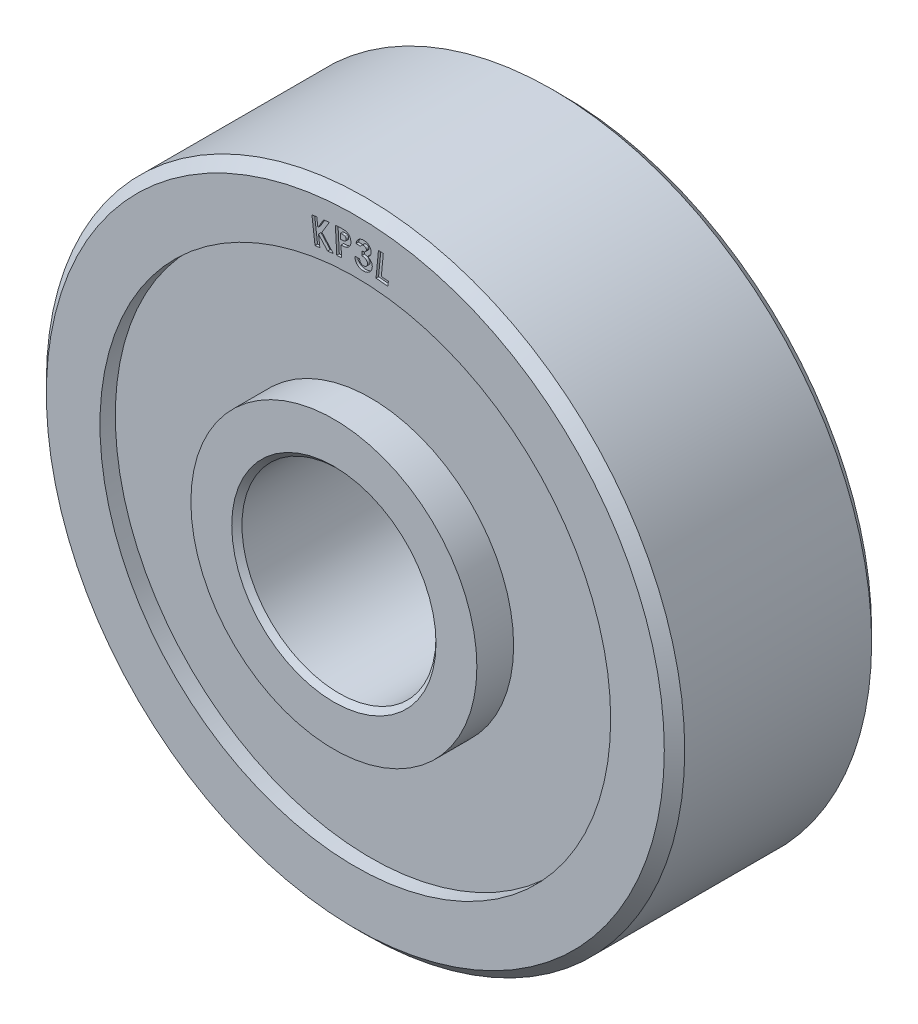
from build123d import *

# Parameters (mm, degrees)
CUT_EXTRUDE1_DEPTH = 0.0635


with BuildPart() as part:
    # Sketch1 → Revolve1 (revolve)
    with BuildSketch(Plane(origin=(0, 0, 0), x_dir=(0, 0, -1), z_dir=(1, 0, 0))):
        Polygon((-3.1115, 2.54), (-3.1115, 3.556), (-2.1971, 3.556), (-2.1971, 6.35), (-2.5781, 6.35), (-2.5781, 7.6835), (-2.3241, 7.9375), (2.3241, 7.9375), (2.5781, 7.6835), (2.5781, 6.35), (2.1971, 6.35), (2.1971, 3.556), (3.1115, 3.556), (3.1115, 2.54), (2.9845, 2.413), (-2.9845, 2.413), align=None)
    revolve(axis=Axis((0, 0, 0), (0, 0, -1)))

    # Sketch2 → Cut-Extrude1 (cut)
    with BuildSketch(Plane.XY.offset(2.5781)):
        Polygon((-1.079278431, 7.150586302), (-0.958816692, 7.165341911), (-0.932358358, 6.950113546), (-0.789127189, 7.186203289), (-0.645768815, 7.203757376), (-0.830213927, 6.897832896), (-0.547694897, 6.580714507), (-0.68889081, 6.563287624), (-0.916076307, 6.817313065), (-0.881985762, 6.539627768), (-1.002447501, 6.524872159), align=None)
        with BuildLine():
            Line((-0.495979722, 7.217923923), (-0.368521789, 7.224792914))
            add(Edge.make_bspline(
                [(-0.368521789, 7.224792914), (-0.360212666, 7.225170877), (-0.344150947, 7.225901489), (-0.320947535, 7.226328926), (-0.29948116, 7.22593657), (-0.27983437, 7.224960601), (-0.26191306, 7.223354515), (-0.245796038, 7.221018467), (-0.231439233, 7.217820211), (-0.218616257, 7.214006305), (-0.206993887, 7.20932123), (-0.196104896, 7.20396297), (-0.185829099, 7.197800596), (-0.175886108, 7.191127057), (-0.166827975, 7.183296649), (-0.15821902, 7.174861669), (-0.150205011, 7.165659009), (-0.142705457, 7.155796819), (-0.135950471, 7.145199124), (-0.129991296, 7.133997768), (-0.124746833, 7.122230733), (-0.120261866, 7.109877238), (-0.116755714, 7.096880858), (-0.113969598, 7.083372622), (-0.111855418, 7.069320908), (-0.111245338, 7.059732154), (-0.11093465, 7.054849003)],
                knots=[0, 0, 0, 0, 2.4953e-05, 4.8234e-05, 6.9608e-05, 8.935e-05, 0.000107236, 0.00012357, 0.000138168, 0.000151326, 0.000163656, 0.000175717, 0.000187693, 0.000199584, 0.000211588, 0.000223551, 0.000235721, 0.000248161, 0.000260688, 0.000273379, 0.000286191, 0.000299308, 0.000312763, 0.000326534, 0.000340673, 0.000355347, 0.000355347, 0.000355347, 0.000355347], degree=3))
            add(Edge.make_bspline(
                [(-0.11093465, 7.054849003), (-0.110712208, 7.049463954), (-0.110274042, 7.038856482), (-0.111260519, 7.023250479), (-0.113172236, 7.008253328), (-0.115979501, 6.993862027), (-0.120280665, 6.980201042), (-0.125502413, 6.967120052), (-0.131815769, 6.954637956), (-0.139429175, 6.94295352), (-0.147744879, 6.931849276), (-0.157121576, 6.921682198), (-0.16719465, 6.912185967), (-0.17816929, 6.903558165), (-0.189907814, 6.895658245), (-0.202410471, 6.888479224), (-0.215833366, 6.882227542), (-0.225221483, 6.878774839), (-0.22999715, 6.877018475)],
                knots=[0, 0, 0, 0, 1.6159e-05, 3.1831e-05, 4.6835e-05, 6.1504e-05, 7.5747e-05, 8.9731e-05, 0.000103726, 0.000117628, 0.000131519, 0.000145295, 0.000159065, 0.000173011, 0.000187123, 0.00020148, 0.00021622, 0.00023148, 0.00023148, 0.00023148, 0.00023148], degree=3))
            add(Edge.make_bspline(
                [(-0.22999715, 6.877018475), (-0.233124685, 6.876048914), (-0.239956759, 6.873930916), (-0.251226836, 6.871359321), (-0.26429545, 6.868935856), (-0.279152272, 6.866813438), (-0.295831543, 6.864965084), (-0.314313901, 6.863141326), (-0.334593332, 6.861681825), (-0.348719697, 6.860808402), (-0.356055844, 6.860354813)],
                knots=[0, 0, 0, 0, 9.82e-06, 2.1452e-05, 3.465e-05, 4.9689e-05, 6.6462e-05, 8.4992e-05, 0.000105402, 0.000127452, 0.000127452, 0.000127452, 0.000127452], degree=3))
            Line((-0.356055844, 6.860354813), (-0.341554642, 6.592845798))
            Line((-0.341554642, 6.592845798), (-0.461761973, 6.586358418))
            Line((-0.461761973, 6.586358418), (-0.495979722, 7.217923923))
        make_face()
        with BuildLine():
            Line((-0.36241602, 6.97750926), (-0.324254962, 6.979544516))
            add(Edge.make_bspline(
                [(-0.324254962, 6.979544516), (-0.317336689, 6.9799779), (-0.30457489, 6.980777342), (-0.287251836, 6.982919527), (-0.273270267, 6.985391536), (-0.262381832, 6.988846741), (-0.253744174, 6.993269306), (-0.246573864, 6.998590644), (-0.240166571, 7.004690808), (-0.235137389, 7.012026135), (-0.231168805, 7.020125976), (-0.22826413, 7.028965777), (-0.227100928, 7.038620455), (-0.227165491, 7.04522278), (-0.227198672, 7.048616031)],
                knots=[0, 0, 0, 0, 2.079e-05, 3.8351e-05, 5.2346e-05, 6.3328e-05, 7.2487e-05, 8.1316e-05, 9.0041e-05, 9.8899e-05, 0.00010783, 0.000117043, 0.000126667, 0.000136844, 0.000136844, 0.000136844, 0.000136844], degree=3))
            add(Edge.make_bspline(
                [(-0.227198672, 7.048616031), (-0.227427705, 7.051549895), (-0.227873088, 7.057255149), (-0.229642727, 7.065434523), (-0.232402977, 7.072908038), (-0.235754963, 7.079834319), (-0.240186228, 7.08601448), (-0.245412186, 7.091546709), (-0.251632427, 7.096260741), (-0.256171905, 7.098908266), (-0.258490739, 7.100260662)],
                knots=[0, 0, 0, 0, 8.822e-06, 1.7156e-05, 2.5002e-05, 3.2682e-05, 4.0164e-05, 4.7722e-05, 5.5431e-05, 6.3481e-05, 6.3481e-05, 6.3481e-05, 6.3481e-05], degree=3))
            add(Edge.make_bspline(
                [(-0.258490739, 7.100260662), (-0.260424076, 7.1011524), (-0.264539471, 7.103050595), (-0.271515666, 7.105142732), (-0.279542151, 7.106932906), (-0.288692612, 7.108156212), (-0.29888814, 7.108858012), (-0.310132208, 7.109270509), (-0.322479434, 7.109086136), (-0.331082448, 7.108720089), (-0.335576076, 7.108528891)],
                knots=[0, 0, 0, 0, 6.38e-06, 1.3582e-05, 2.1791e-05, 3.1038e-05, 4.1243e-05, 5.2443e-05, 6.4782e-05, 7.8276e-05, 7.8276e-05, 7.8276e-05, 7.8276e-05], degree=3))
            Line((-0.335576076, 7.108528891), (-0.369412214, 7.106748042))
            Line((-0.369412214, 7.106748042), (-0.36241602, 6.97750926))
        make_face(mode=Mode.SUBTRACT)
        with BuildLine():
            Line((0.132952806, 7.075773457), (0.017452005, 7.078444732))
            add(Edge.make_bspline(
                [(0.017452005, 7.078444732), (0.018439502, 7.084140821), (0.02036877, 7.095269235), (0.024442732, 7.111454443), (0.02968473, 7.126689428), (0.035796855, 7.141101973), (0.042752408, 7.154721258), (0.050980538, 7.167270992), (0.059964236, 7.179124945), (0.066817376, 7.186208566), (0.070241468, 7.189747816)],
                knots=[0, 0, 0, 0, 1.7339e-05, 3.3876e-05, 5.0007e-05, 6.5624e-05, 8.0814e-05, 9.581e-05, 0.000110592, 0.000125353, 0.000125353, 0.000125353, 0.000125353], degree=3))
            add(Edge.make_bspline(
                [(0.070241468, 7.189747816), (0.075192439, 7.194396641), (0.084970062, 7.203577557), (0.101150249, 7.215276904), (0.118160824, 7.225212143), (0.136146121, 7.233001378), (0.154887577, 7.239258861), (0.174558992, 7.243383937), (0.195137536, 7.24575924), (0.20914139, 7.245731494), (0.216271115, 7.245717368)],
                knots=[0, 0, 0, 0, 2.0357e-05, 4.0202e-05, 5.9751e-05, 7.9344e-05, 9.8893e-05, 0.000118928, 0.000139535, 0.000160908, 0.000160908, 0.000160908, 0.000160908], degree=3))
            add(Edge.make_bspline(
                [(0.216271115, 7.245717368), (0.222643467, 7.245466741), (0.235151233, 7.244974808), (0.253386088, 7.242017246), (0.270855675, 7.237931701), (0.287404435, 7.2319532), (0.30331457, 7.224796151), (0.318192998, 7.215727901), (0.332473067, 7.205471618), (0.345463167, 7.193482998), (0.357578641, 7.18085237), (0.367877659, 7.167233243), (0.376733752, 7.153233008), (0.383946054, 7.138680055), (0.389270466, 7.123490973), (0.393157806, 7.107832343), (0.395181679, 7.091559114), (0.395309178, 7.080569756), (0.39537368, 7.075010236)],
                knots=[0, 0, 0, 0, 1.9115e-05, 3.7519e-05, 5.5321e-05, 7.2862e-05, 9.0222e-05, 0.000107565, 0.000125044, 0.000142876, 0.000160514, 0.000177484, 0.000194001, 0.000210157, 0.00022609, 0.000242194, 0.000258477, 0.000275148, 0.000275148, 0.000275148, 0.000275148], degree=3))
            add(Edge.make_bspline(
                [(0.39537368, 7.075010236), (0.394948635, 7.068113053), (0.394112348, 7.054542638), (0.389195825, 7.034731031), (0.381559766, 7.015944127), (0.370990163, 6.998289072), (0.357888482, 6.981930636), (0.341973374, 6.967324387), (0.323568287, 6.954335464), (0.309826078, 6.947500387), (0.302769513, 6.943990605)],
                knots=[0, 0, 0, 0, 2.0695e-05, 4.0718e-05, 6.0915e-05, 8.1334e-05, 0.000102233, 0.000123566, 0.000145939, 0.000169554, 0.000169554, 0.000169554, 0.000169554], degree=3))
            add(Edge.make_bspline(
                [(0.302769513, 6.943990605), (0.307410197, 6.942346114), (0.316543415, 6.939109632), (0.329714867, 6.933441478), (0.341966279, 6.926702638), (0.353553282, 6.919456552), (0.364163573, 6.911144273), (0.374175204, 6.902319711), (0.3831394, 6.892437959), (0.391453576, 6.882031606), (0.398832047, 6.87097474), (0.405172288, 6.859381433), (0.410586141, 6.847416845), (0.414753855, 6.834905001), (0.418129223, 6.822003125), (0.420171265, 6.808572723), (0.421593917, 6.794769054), (0.42149875, 6.785413976), (0.421450402, 6.780661278)],
                knots=[0, 0, 0, 0, 1.4769e-05, 2.9067e-05, 4.2955e-05, 5.6682e-05, 7.0014e-05, 8.3345e-05, 9.6668e-05, 0.000109979, 0.000123279, 0.000136487, 0.000149583, 0.000162617, 0.000176006, 0.000189537, 0.000203333, 0.000217581, 0.000217581, 0.000217581, 0.000217581], degree=3))
            add(Edge.make_bspline(
                [(0.421450402, 6.780661278), (0.421137547, 6.773692656), (0.420521475, 6.759970097), (0.416962861, 6.73989903), (0.411608007, 6.720680255), (0.404369139, 6.702253524), (0.394989968, 6.684764153), (0.383739054, 6.66813578), (0.370500347, 6.652435227), (0.355614031, 6.637640856), (0.339196026, 6.624217045), (0.321513765, 6.6126142), (0.30292282, 6.60268693), (0.283132961, 6.595031176), (0.262467464, 6.588750355), (0.240650353, 6.584861887), (0.217854829, 6.582417398), (0.202327811, 6.582457625), (0.194392109, 6.582478185)],
                knots=[0, 0, 0, 0, 2.0908e-05, 4.1172e-05, 6.0987e-05, 8.0687e-05, 0.000100433, 0.000120402, 0.00014081, 0.000161947, 0.000183284, 0.000204311, 0.000225307, 0.000246378, 0.00026787, 0.00029, 0.000312757, 0.000336547, 0.000336547, 0.000336547, 0.000336547], degree=3))
            add(Edge.make_bspline(
                [(0.194392109, 6.582478185), (0.186919369, 6.58282211), (0.172255171, 6.583497015), (0.150835798, 6.586574284), (0.130497736, 6.591357491), (0.111348115, 6.598083664), (0.093157646, 6.606157207), (0.076136666, 6.61614531), (0.060312838, 6.627964977), (0.045551967, 6.641275516), (0.032219364, 6.656095091), (0.020628377, 6.672290052), (0.010395444, 6.689520266), (0.002265312, 6.70822003), (-0.004597546, 6.727960124), (-0.009429015, 6.748999425), (-0.013018339, 6.771178485), (-0.013814397, 6.786455887), (-0.014221673, 6.794272055)],
                knots=[0, 0, 0, 0, 2.2432e-05, 4.4019e-05, 6.4814e-05, 8.5008e-05, 0.000104821, 0.000124434, 0.000144074, 0.000163977, 0.000183974, 0.000203745, 0.000223642, 0.000243971, 0.000264808, 0.000286251, 0.000308649, 0.000332113, 0.000332113, 0.000332113, 0.000332113], degree=3))
            Line((-0.014221673, 6.794272055), (0.104713623, 6.791600781))
            add(Edge.make_bspline(
                [(0.104713623, 6.791600781), (0.105298242, 6.787648337), (0.106442918, 6.779909505), (0.10897651, 6.768767308), (0.11214082, 6.758379616), (0.116023947, 6.748810364), (0.120250343, 6.739882058), (0.125265864, 6.73179494), (0.130884536, 6.724538734), (0.138989247, 6.715854693), (0.150749392, 6.70694287), (0.166646166, 6.698857642), (0.184491711, 6.693980795), (0.196991331, 6.693177178), (0.203423559, 6.692763642)],
                knots=[0, 0, 0, 0, 1.1983e-05, 2.3462e-05, 3.4245e-05, 4.452e-05, 5.4419e-05, 6.3845e-05, 7.3004e-05, 8.1913e-05, 9.9418e-05, 0.000116939, 0.000135146, 0.000154449, 0.000154449, 0.000154449, 0.000154449], degree=3))
            add(Edge.make_bspline(
                [(0.203423559, 6.692763642), (0.206860174, 6.692795324), (0.213622469, 6.692857667), (0.223550981, 6.693858773), (0.233054921, 6.69577148), (0.242072931, 6.698585144), (0.250700473, 6.702158131), (0.258884157, 6.706643003), (0.266615515, 6.711997907), (0.273914613, 6.718078277), (0.2803679, 6.724941505), (0.286382645, 6.732009814), (0.291170091, 6.739758067), (0.29525823, 6.747796346), (0.298653731, 6.75618868), (0.300850093, 6.765063604), (0.3024752, 6.774244196), (0.302754844, 6.780526788), (0.302896716, 6.783714163)],
                knots=[0, 0, 0, 0, 1.0307e-05, 2.0281e-05, 2.9885e-05, 3.934e-05, 4.8577e-05, 5.7856e-05, 6.7277e-05, 7.6756e-05, 8.6292e-05, 9.551e-05, 0.000104544, 0.000113533, 0.000122556, 0.000131627, 0.000140912, 0.000150473, 0.000150473, 0.000150473, 0.000150473], degree=3))
            add(Edge.make_bspline(
                [(0.302896716, 6.783714163), (0.302855919, 6.787239361), (0.302775869, 6.794156143), (0.301169919, 6.804358986), (0.298502676, 6.814176672), (0.294709018, 6.823666411), (0.289517199, 6.832626427), (0.283192844, 6.841187214), (0.275847002, 6.849525611), (0.267111799, 6.857175477), (0.257543603, 6.864561228), (0.246603097, 6.8706581), (0.234838955, 6.876244408), (0.221911444, 6.880780534), (0.207950127, 6.884434754), (0.192934801, 6.887182182), (0.176934422, 6.889307109), (0.165863133, 6.889802013), (0.160174361, 6.89005631)],
                knots=[0, 0, 0, 0, 1.0565e-05, 2.0729e-05, 3.0882e-05, 4.1039e-05, 5.1294e-05, 6.1853e-05, 7.2934e-05, 8.4554e-05, 9.6639e-05, 0.000109119, 0.000122037, 0.000135676, 0.000150147, 0.00016529, 0.000181447, 0.000198522, 0.000198522, 0.000198522, 0.000198522], degree=3))
            Line((0.160174361, 6.89005631), (0.162464024, 6.993091166))
            add(Edge.make_bspline(
                [(0.162464024, 6.993091166), (0.169254634, 6.993562952), (0.181985765, 6.994447465), (0.199670274, 6.996852343), (0.214559817, 7.000416319), (0.227059167, 7.004696582), (0.237467933, 7.010260276), (0.246596701, 7.016448033), (0.254479519, 7.023725698), (0.261202937, 7.031782392), (0.266544619, 7.040599334), (0.270543684, 7.049783218), (0.273053496, 7.05936446), (0.273528195, 7.065879749), (0.273767109, 7.069158874)],
                knots=[0, 0, 0, 0, 2.042e-05, 3.8283e-05, 5.3462e-05, 6.6297e-05, 7.7791e-05, 8.8764e-05, 9.9298e-05, 0.000109868, 0.000120143, 0.000130114, 0.000139833, 0.00014968, 0.00014968, 0.00014968, 0.00014968], degree=3))
            add(Edge.make_bspline(
                [(0.273767109, 7.069158874), (0.273647051, 7.073294497), (0.27341287, 7.081361296), (0.270088767, 7.092887755), (0.264605858, 7.103405251), (0.256838453, 7.112591201), (0.247262907, 7.120275972), (0.236075166, 7.125995676), (0.223378441, 7.129443865), (0.214426945, 7.130036412), (0.209783736, 7.13034377)],
                knots=[0, 0, 0, 0, 1.2371e-05, 2.413e-05, 3.5624e-05, 4.7725e-05, 5.9942e-05, 7.223e-05, 8.5161e-05, 9.9096e-05, 9.9096e-05, 9.9096e-05, 9.9096e-05], degree=3))
            add(Edge.make_bspline(
                [(0.209783736, 7.13034377), (0.205571739, 7.130279924), (0.197225626, 7.130153411), (0.184957735, 7.127345618), (0.173301252, 7.122579626), (0.162373454, 7.115992851), (0.152702795, 7.107728295), (0.144200462, 7.09836227), (0.137538917, 7.087595633), (0.134487306, 7.079729123), (0.132952806, 7.075773457)],
                knots=[0, 0, 0, 0, 1.2609e-05, 2.4985e-05, 3.7481e-05, 5.0265e-05, 6.3083e-05, 7.5516e-05, 8.8083e-05, 0.000100794, 0.000100794, 0.000100794, 0.000100794], degree=3))
        make_face()
        Polygon((0.5754121, 7.213728858), (0.695619431, 7.202280541), (0.645882853, 6.685325413), (0.821042108, 6.668407344), (0.809975401, 6.553796967), (0.514608814, 6.582163354), align=None)
    extrude(amount=-CUT_EXTRUDE1_DEPTH, mode=Mode.SUBTRACT)


solid = part.part
